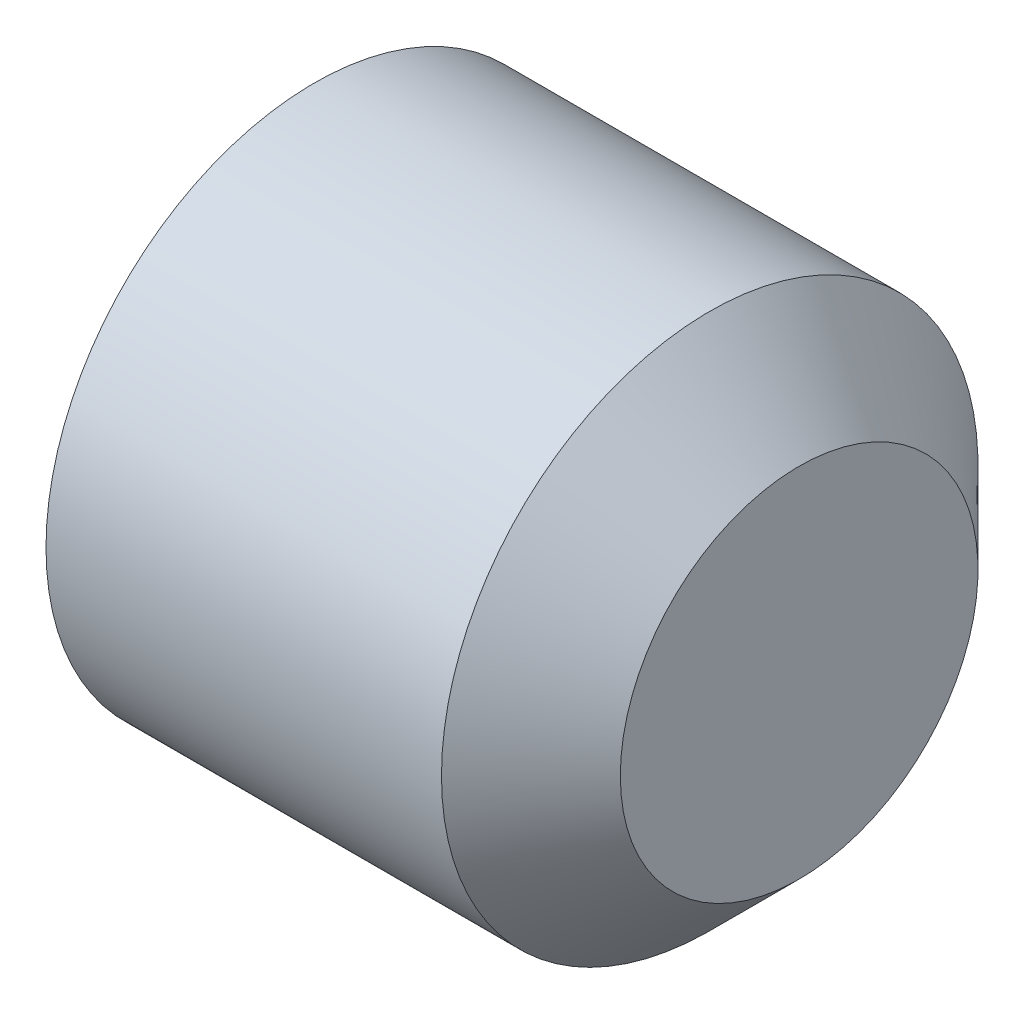
from build123d import *

# Parameters (mm, degrees)
CUT_EXTRUDE_1_DEPTH = 2
CHAMFER_1_SIZE      = 1
CHAMFER_1_SIZE2     = 0.577350269
FILLET_1_R          = 0.1


with BuildPart() as part:
    # Эскиз1 → Повернуть1 (revolve)
    with BuildSketch(Plane(origin=(0, 0, 0), x_dir=(-1, 0, 0), z_dir=(0, 0, -1))):
        Polygon((-6, 2), (-6, 0), (0, 0), (0, 3), (-5, 3), align=None)
    revolve(axis=Axis((6, 0, 0), (-1, 0, 0)))

    # Эскиз2 → Вырез-Вытянуть1 (cut)
    with BuildSketch(Plane.ZY):
        Polygon((1.732050808, 0), (0.866025404, 1.5), (-0.866025404, 1.5), (-1.732050808, 0), (-0.866025404, -1.5), (0.866025404, -1.5), align=None)
    extrude(amount=-CUT_EXTRUDE_1_DEPTH, mode=Mode.SUBTRACT)

    # Фаска1
    chamfer_1_edges = [part.edges().sort_by_distance(p)[0] for p in [
        (0, -3, 0),
    ]]
    chamfer_1_side = [part.faces().sort_by_distance(p)[0] for p in [
        (0, -2.915147186, 0),
    ]]
    chamfer(chamfer_1_edges, length=CHAMFER_1_SIZE, length2=CHAMFER_1_SIZE2, reference=chamfer_1_side[0])

    # Скругление1
    fillet_1_edges = [part.edges().sort_by_distance(p)[0] for p in [
        (2, -0.75, 1.299038106),
        (2, -1.5, 0),
        (2, -0.75, -1.299038106),
        (2, 0.75, -1.299038106),
        (2, 1.5, 0),
        (2, 0.75, 1.299038106),
        (0, -0.75, 1.299038106),
        (0, 0.75, 1.299038106),
        (0, 1.5, 0),
        (0, 0.75, -1.299038106),
        (0, -0.75, -1.299038106),
        (0, -1.5, 0),
        (0, -2, 0),
    ]]
    fillet(fillet_1_edges, radius=FILLET_1_R)


solid = part.part
